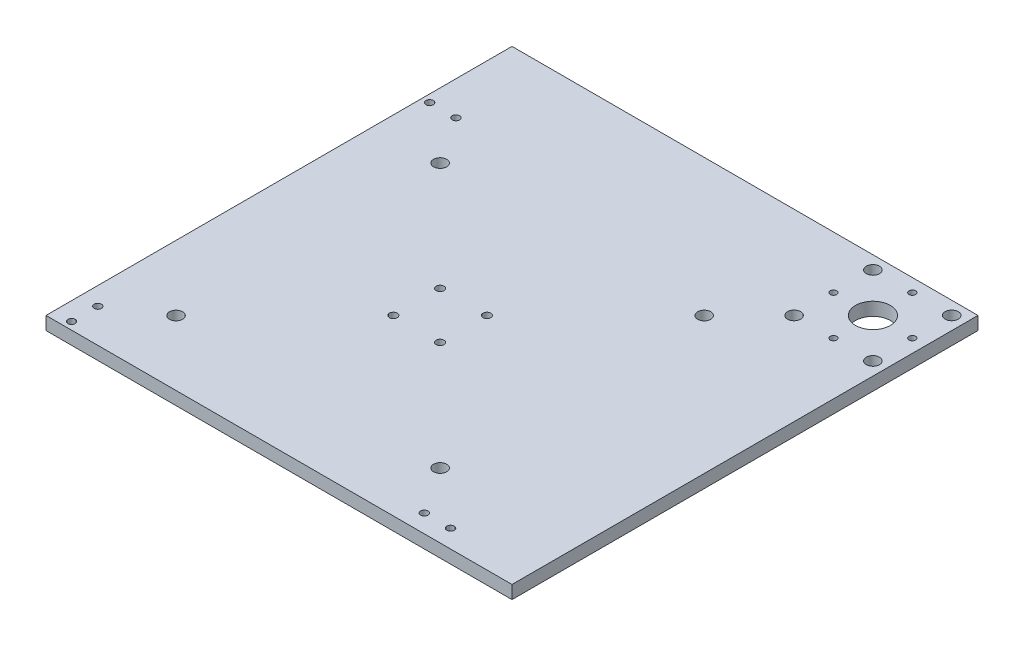
from build123d import *

# Parameters (mm, degrees)
SKETCH1_W           = 190.5
SKETCH1_H           = 190.5
SKETCH1_R           = 1.905
SKETCH1_R_2         = 1.778
BOSS_EXTRUDE1_DEPTH = 6.35
BOSS_EXTRUDE3_DEPTH = 6.35
SKETCH8_R           = 3.175
CUT_EXTRUDE1_DEPTH  = 7.35
SKETCH9_R           = 3.175
CUT_EXTRUDE2_DEPTH  = 7.35
SKETCH10_R          = 1.5875
CUT_EXTRUDE3_DEPTH  = 7.35
SKETCH11_R          = 8.41375
CUT_EXTRUDE4_DEPTH  = 7.35


with BuildPart() as part:
    # Sketch1 → Boss-Extrude1 (new body)
    with BuildSketch(Plane(origin=(0, 0, 0), x_dir=(1, 0, 0), z_dir=(0, 1, 0))):
        Rectangle(SKETCH1_W, SKETCH1_H)
        with Locations((-11.303, 11.303)):
            Circle(SKETCH1_R, mode=Mode.SUBTRACT)
        with Locations((-11.303, -11.303)):
            Circle(SKETCH1_R, mode=Mode.SUBTRACT)
        with Locations((11.303, 11.303)):
            Circle(SKETCH1_R, mode=Mode.SUBTRACT)
        with Locations((11.303, -11.303)):
            Circle(SKETCH1_R, mode=Mode.SUBTRACT)
        with Locations((-78.9, 86.55)):
            Circle(SKETCH1_R_2, mode=Mode.SUBTRACT)
        with Locations((-91.6, 86.55)):
            Circle(SKETCH1_R_2, mode=Mode.SUBTRACT)
        with Locations((91.6, -86.55)):
            Circle(SKETCH1_R_2, mode=Mode.SUBTRACT)
        with Locations((78.9, -86.55)):
            Circle(SKETCH1_R_2, mode=Mode.SUBTRACT)
        with Locations((-86.55, -78.9)):
            Circle(SKETCH1_R_2, mode=Mode.SUBTRACT)
        with Locations((-86.55, -91.6)):
            Circle(SKETCH1_R_2, mode=Mode.SUBTRACT)
    extrude(amount=BOSS_EXTRUDE1_DEPTH)

    # Sketch7 → Boss-Extrude3 (add)
    with BuildSketch(Plane.XZ):
        Polygon((-95.25, -130), (78.2, -130), (130, -130), (130, -78.2), (130, 95.25), (95.25, 95.25), (95.25, -95.25), (-95.25, -95.25), align=None)
    extrude(amount=-BOSS_EXTRUDE3_DEPTH)

    # Sketch8 → Cut-Extrude1 (cut, through all)
    with BuildSketch(Plane.XZ):
        with Locations((-63.77864005, -63.77864005)):
            Circle(SKETCH8_R)
        with Locations((-63.77864005, 63.87464005)):
            Circle(SKETCH8_R)
        with Locations((63.87464005, 63.87464005)):
            Circle(SKETCH8_R)
        with Locations((63.87464005, -63.77864005)):
            Circle(SKETCH8_R)
    extrude(amount=-CUT_EXTRUDE1_DEPTH, mode=Mode.SUBTRACT)

    # Sketch9 → Cut-Extrude2 (cut, through all)
    with BuildSketch(Plane.XZ):
        with Locations((123.65, -123.65)):
            Circle(SKETCH9_R)
        with Locations((85.55, -85.55)):
            Circle(SKETCH9_R)
        with Locations((123.65, -85.55)):
            Circle(SKETCH9_R)
        with Locations((85.55, -123.65)):
            Circle(SKETCH9_R)
    extrude(amount=-CUT_EXTRUDE2_DEPTH, mode=Mode.SUBTRACT)

    # Sketch10 → Cut-Extrude3 (cut, through all)
    with BuildSketch(Plane.XZ):
        with Locations((104.6, -123.65)):
            Circle(SKETCH10_R)
        with Locations((85.55, -104.6)):
            Circle(SKETCH10_R)
        with Locations((104.6, -85.55)):
            Circle(SKETCH10_R)
        with Locations((123.65, -104.6)):
            Circle(SKETCH10_R)
    extrude(amount=-CUT_EXTRUDE3_DEPTH, mode=Mode.SUBTRACT)

    # Sketch11 → Cut-Extrude4 (cut, through all)
    with BuildSketch(Plane.XZ):
        with Locations((104.6, -104.6)):
            Circle(SKETCH11_R)
    extrude(amount=-CUT_EXTRUDE4_DEPTH, mode=Mode.SUBTRACT)


solid = part.part
